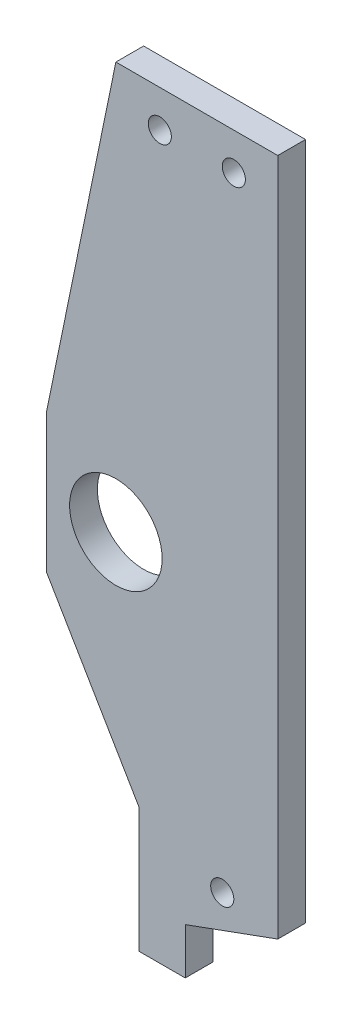
from build123d import *

# Parameters (mm, degrees)
SKETCH1_W           = 10
SKETCH1_H           = 77
BOSS_EXTRUDE1_DEPTH = 3
SKETCH2_W           = 15
SKETCH2_H           = 15
BOSS_EXTRUDE2_DEPTH = 3
BOSS_EXTRUDE3_DEPTH = 3
BOSS_EXTRUDE4_DEPTH = 3
SKETCH5_R           = 5
SKETCH5_R_2         = 1.25
CUT_EXTRUDE1_DEPTH  = 3
CUT_EXTRUDE2_DEPTH  = 10


with BuildPart() as part:
    # Sketch1 → Boss-Extrude1 (new body)
    with BuildSketch(Plane.XY):
        with Locations((-28.110071178, -14.958795526)):
            Rectangle(SKETCH1_W, SKETCH1_H)
    extrude(amount=BOSS_EXTRUDE1_DEPTH)

    # Sketch2 → Boss-Extrude2 (add)
    with BuildSketch(Plane.XY.offset(3)):
        with Locations((-40.610071178, -20.458795526)):
            Rectangle(SKETCH2_W, SKETCH2_H)
    extrude(amount=-BOSS_EXTRUDE2_DEPTH)

    # Sketch3 → Boss-Extrude3 (add)
    with BuildSketch(Plane.XY.offset(3)):
        Polygon((-33.110071178, 23.541204474), (-40.610071178, 23.541204474), (-48.110071178, -12.958795526), (-33.110071178, -12.958795526), align=None)
        Polygon((-48.110071178, -27.958795526), (-33.110071178, -53.458795526), (-33.110071178, -27.958795526), align=None)
    extrude(amount=-BOSS_EXTRUDE3_DEPTH)

    # Sketch4 → Boss-Extrude4 (add)
    with BuildSketch(Plane.XY.offset(3)):
        Polygon((-33.110071178, -53.458795526), (-33.110071178, -58.458795526), (-38.110071178, -58.458795526), (-38.110071178, -44.958795526), align=None)
    extrude(amount=-BOSS_EXTRUDE4_DEPTH)

    # Sketch5 → Cut-Extrude1 (cut)
    with BuildSketch(Plane.XY.offset(3)):
        with Locations((-40.610071178, -20.458795526)):
            Circle(SKETCH5_R)
        with Locations((-29.110071178, -48.458795526)):
            Circle(SKETCH5_R_2)
        with Locations((-35.860071178, 19.541204474)):
            Circle(SKETCH5_R_2)
        with Locations((-27.860071178, 19.541204474)):
            Circle(SKETCH5_R_2)
    extrude(amount=-CUT_EXTRUDE1_DEPTH, mode=Mode.SUBTRACT)

    # Sketch6 → Cut-Extrude2 (cut)
    with BuildSketch(Plane(origin=(0, 0, 0), x_dir=(-1, 0, 0), z_dir=(0, 0, -1))):
        Polygon((23.110071178, -49.817142067), (23.110071178, -53.458795526), (33.110071178, -53.458795526), align=None)
    extrude(amount=-CUT_EXTRUDE2_DEPTH, mode=Mode.SUBTRACT)


solid = part.part
